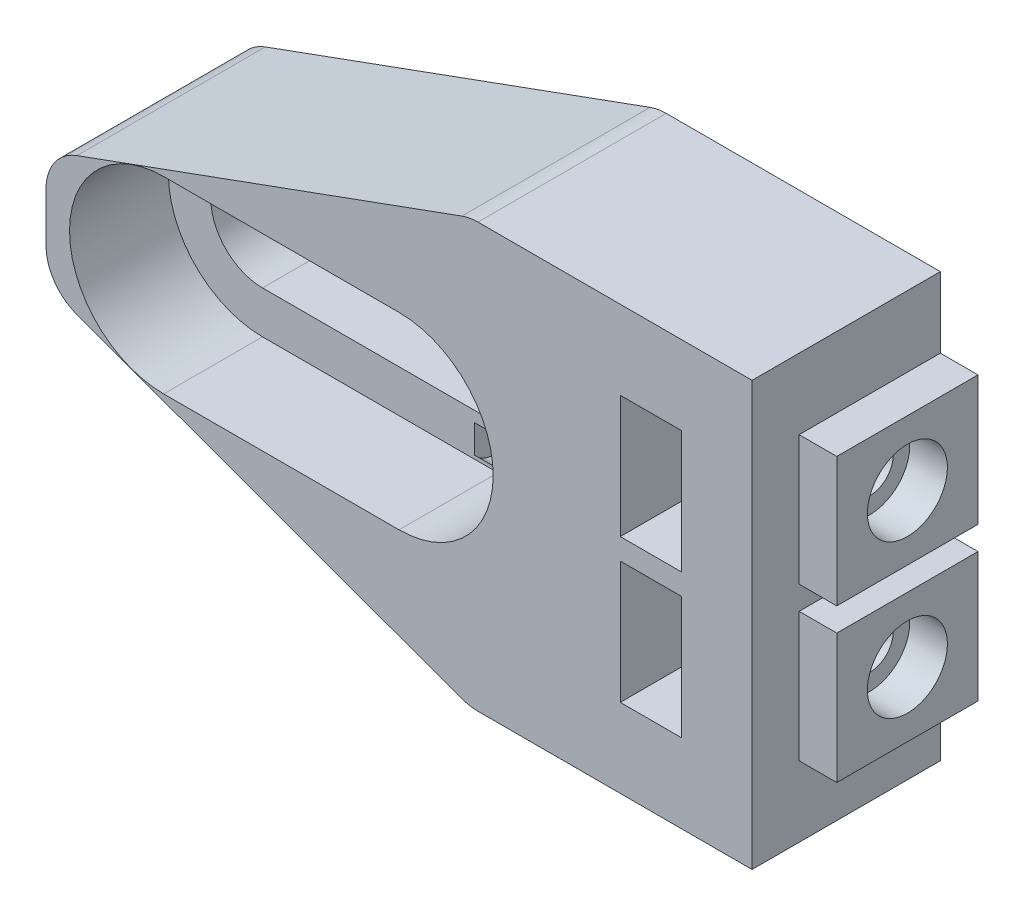
from build123d import *

# Parameters (mm, degrees)
ESQUISSE1_W             = 30
ESQUISSE1_H             = 18
BOSS_EXTRU_1_DEPTH      = 8
ENL_V_MAT_EXTRU_1_DEPTH = 9
ENL_V_MAT_EXTRU_2_DEPTH = 4.2
CHANFREIN1_SIZE         = 18
CHANFREIN1_SIZE2        = 6.551464217
CHANFREIN1_PART_2_SIZE  = 18
CHANFREIN1_PART_2_SIZE2 = 6.551464217
CONG_1_R                = 2
ESQUISSE4_W             = 2.6
ESQUISSE4_H             = 5.2
ENL_V_MAT_EXTRU_3_DEPTH = 9
ESQUISSE5_R             = 1
ENL_V_MAT_EXTRU_4_DEPTH = 16
ESQUISSE6_W             = 6
ESQUISSE6_H             = 5.5
ESQUISSE6_R             = 1.7
BOSS_EXTRU_2_DEPTH      = 1.6


with BuildPart() as part:
    # Esquisse1 → Boss.-Extru.1 (new body)
    with BuildSketch(Plane.XY):
        with Locations((7, 0)):
            Rectangle(ESQUISSE1_W, ESQUISSE1_H)
    extrude(amount=BOSS_EXTRU_1_DEPTH)

    # Esquisse2 → Enlèv. mat.-Extru.1 (cut, through all)
    with BuildSketch(Plane.XY.offset(8)):
        with BuildLine():
            Line((-3, 2.2), (7, 2.2))
            ThreePointArc((7, 2.2), (9.2, 0), (7, -2.2))
            Line((7, -2.2), (-3, -2.2))
            ThreePointArc((-3, -2.2), (-5.2, 0), (-3, 2.2))
        make_face()
    extrude(amount=-ENL_V_MAT_EXTRU_1_DEPTH, mode=Mode.SUBTRACT)

    # Esquisse3 → Enlèv. mat.-Extru.2 (cut)
    with BuildSketch(Plane.XY.offset(8)):
        with BuildLine():
            Line((-3, 4), (7, 4))
            ThreePointArc((7, 4), (11, 0), (7, -4))
            Line((7, -4), (-3, -4))
            ThreePointArc((-3, -4), (-7, 0), (-3, 4))
        make_face()
    extrude(amount=-ENL_V_MAT_EXTRU_2_DEPTH, mode=Mode.SUBTRACT)

    # Chanfrein1
    chanfrein1_edges = [part.edges().sort_by_distance(p)[0] for p in [
        (-8, 9, 4),
    ]]
    chanfrein1_side = [part.faces().sort_by_distance(p)[0] for p in [
        (7, 9, 4),
    ]]
    chamfer(chanfrein1_edges, length=CHANFREIN1_SIZE, length2=CHANFREIN1_SIZE2, reference=chanfrein1_side[0])

    # Chanfrein1 part 2
    chanfrein1_part_2_edges = [part.edges().sort_by_distance(p)[0] for p in [
        (-8, -9, 4),
    ]]
    chanfrein1_part_2_side = [part.faces().sort_by_distance(p)[0] for p in [
        (7, -9, 4),
    ]]
    chamfer(chanfrein1_part_2_edges, length=CHANFREIN1_PART_2_SIZE, length2=CHANFREIN1_PART_2_SIZE2, reference=chanfrein1_part_2_side[0])

    # Congé1
    cong_1_edges = [part.edges().sort_by_distance(p)[0] for p in [
        (10, -9, 4),
        (-8, 2.448535783, 4),
        (-8, -2.448535783, 4),
        (10, 9, 4),
    ]]
    fillet(cong_1_edges, radius=CONG_1_R)

    # Esquisse4 → Enlèv. mat.-Extru.3 (cut, through all)
    with BuildSketch(Plane(origin=(0, 0, 0), x_dir=(-1, 0, 0), z_dir=(0, 0, -1))):
        with Locations((-17.7, -3.05)):
            Rectangle(ESQUISSE4_W, ESQUISSE4_H)
        with Locations((-17.7, 3.05)):
            Rectangle(ESQUISSE4_W, ESQUISSE4_H)
    extrude(amount=-ENL_V_MAT_EXTRU_3_DEPTH, mode=Mode.SUBTRACT)

    # Esquisse5 → Enlèv. mat.-Extru.4 (cut)
    with BuildSketch(Plane(origin=(22, 0, 0), x_dir=(0, 0, -1), z_dir=(1, 0, 0))):
        with Locations((-3, 3.25)):
            Circle(ESQUISSE5_R)
        with Locations((-3, -3.25)):
            Circle(ESQUISSE5_R)
    extrude(amount=-ENL_V_MAT_EXTRU_4_DEPTH, mode=Mode.SUBTRACT)

    # Esquisse6 → Boss.-Extru.2 (add)
    with BuildSketch(Plane(origin=(22, 0, 0), x_dir=(0, 0, -1), z_dir=(1, 0, 0))):
        with Locations((-3, -3.25)):
            Rectangle(ESQUISSE6_W, ESQUISSE6_H)
        with Locations((-3, -3.25)):
            Circle(ESQUISSE6_R, mode=Mode.SUBTRACT)
        with Locations((-3, 3.25)):
            Rectangle(ESQUISSE6_W, ESQUISSE6_H)
        with Locations((-3, 3.25)):
            Circle(ESQUISSE6_R, mode=Mode.SUBTRACT)
    extrude(amount=BOSS_EXTRU_2_DEPTH)


solid = part.part
